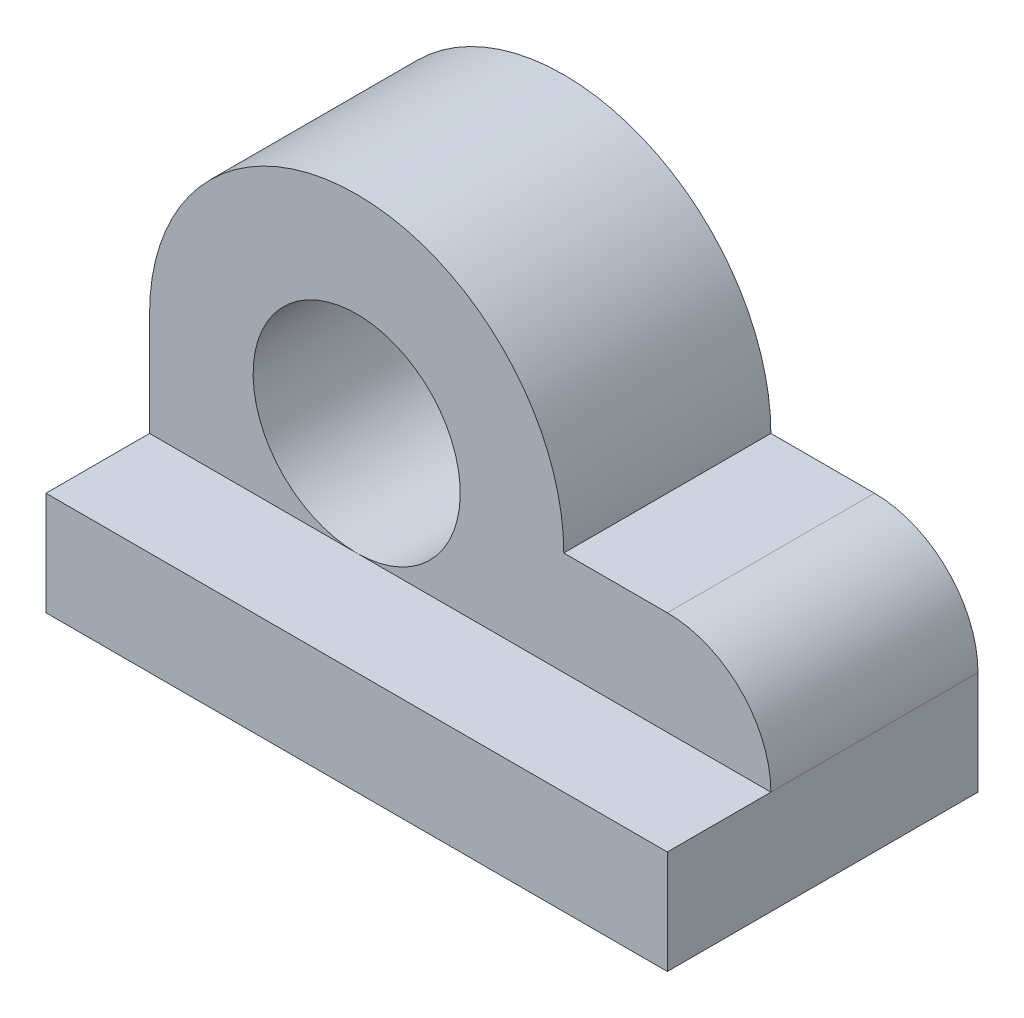
from build123d import *

# Parameters (mm, degrees)
SKETCH_1_R      = 1
EXTRUDE_1_DEPTH = 2
EXTRUDE_2_DEPTH = 3


with BuildPart() as part:
    # 草圖1 → 填料-伸長1 (new body)
    with BuildSketch(Plane.XY):
        with BuildLine():
            ThreePointArc((2, 0), (0, 2), (-2, 0))
            Line((-2, 0), (-2, -2))
            Line((-2, -2), (4, -2))
            Line((4, -2), (4, -1))
            ThreePointArc((4, -1), (3.707106781, -0.292893219), (3, 0))
            Line((3, 0), (2, 0))
        make_face()
        Circle(SKETCH_1_R, mode=Mode.SUBTRACT)
    extrude(amount=EXTRUDE_1_DEPTH)

    # 草圖1<3> → 填料-伸長2 (add)
    with BuildSketch(Plane.XY):
        Polygon((0, -1), (-2, -1), (-2, -2), (4, -2), (4, -1), align=None)
    extrude(amount=EXTRUDE_2_DEPTH)


solid = part.part
